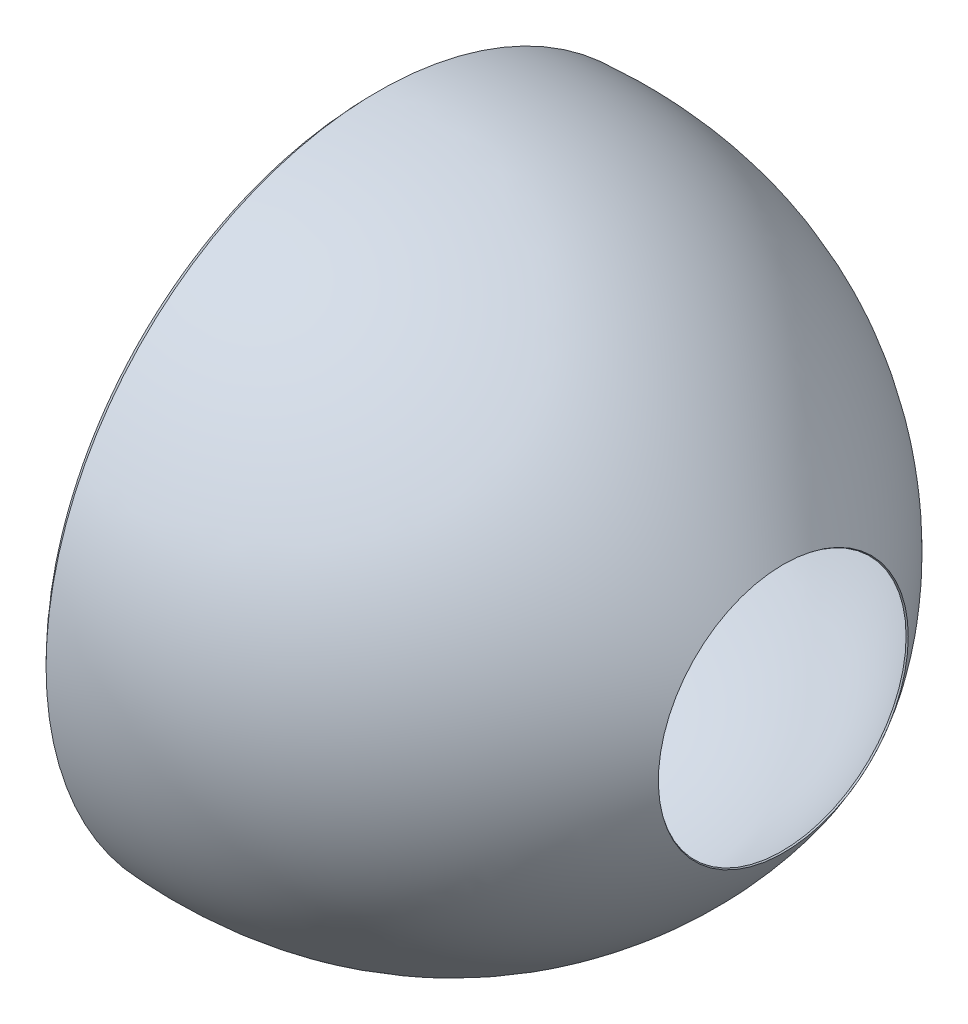
from build123d import *

# Parameters (mm, degrees)
THICKEN1_T1 = 5


with BuildPart() as body_1:
    # Surface-Revolve1: a surface, the sketch's curves turned about an axis
    with BuildLine(Plane.XY, mode=Mode.PRIVATE) as surface_revolve1_1_path:
        Line((58.164522356, 920), (33.164522356, 920))
        Line((33.164522356, 920), (25, 900))
        Line((25, 900), (0, 900))
        add(Edge.make_bspline(
            [(0, 900), (-96.66447243, 975.239483691), (0, 1065.934358968)],
            knots=[0, 0, 0, 1, 1, 1], degree=2))
        add(Edge.make_bspline(
            [(0, 1065.934358968), (802.443853744, 1115.265873196), (1300, 400)],
            knots=[0, 0, 0, 1, 1, 1], degree=2))
    surface_revolve1_1 = Shell.revolve(surface_revolve1_1_path.wire(), 360, Axis((0, 0, 0), (1, 0, 0)))
    add(Solid.thicken(surface_revolve1_1, THICKEN1_T1))


solid = body_1.part
